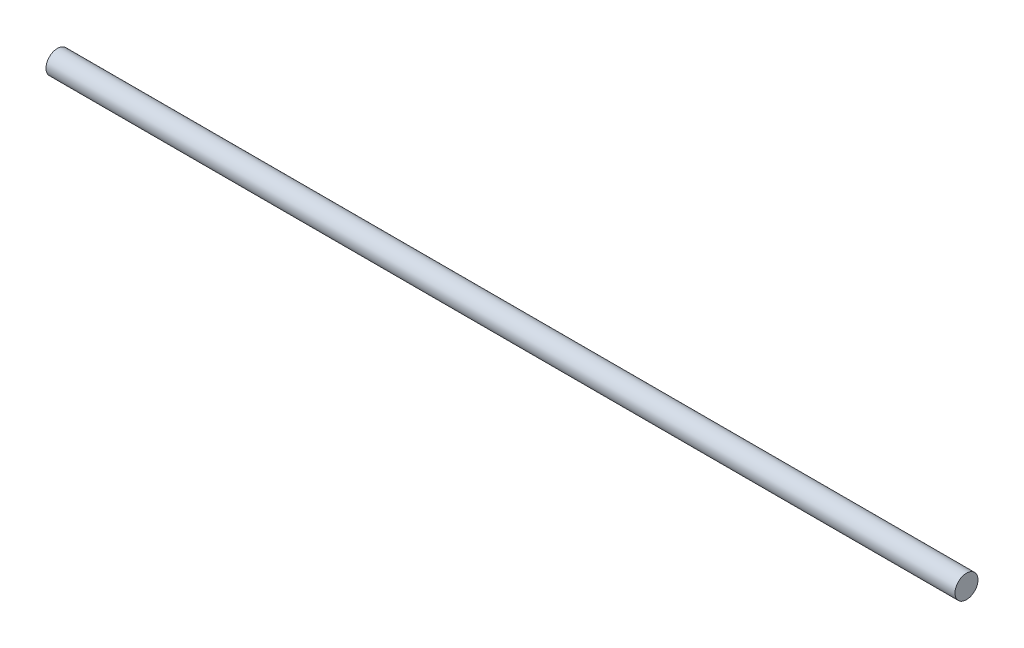
from build123d import *

# Parameters (mm, degrees)
SKETCH1_R           = 6.35
BOSS_EXTRUDE1_DEPTH = 501.3


with BuildPart() as part:
    # Sketch1 → Boss-Extrude1 (new body)
    with BuildSketch(Plane(origin=(0, 0, 0), x_dir=(0, 0, -1), z_dir=(1, 0, 0))):
        Circle(SKETCH1_R)
    extrude(amount=BOSS_EXTRUDE1_DEPTH)


solid = part.part
